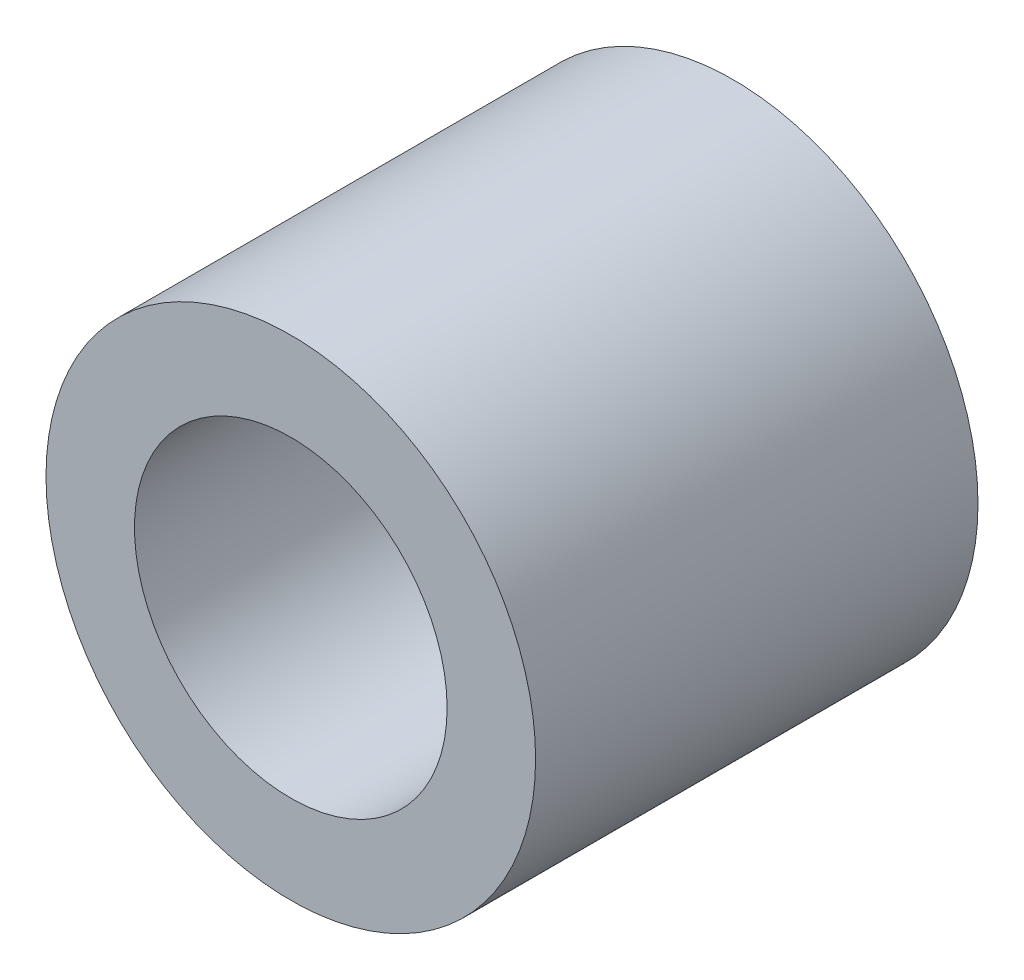
from build123d import *

# Parameters (mm, degrees)
SKETCH1_R           = 4.15
SKETCH1_R_2         = 2.65
BOSS_EXTRUDE1_DEPTH = 7.5


with BuildPart() as part:
    # Sketch1 → Boss-Extrude1 (new body)
    with BuildSketch(Plane.XY):
        Circle(SKETCH1_R)
        Circle(SKETCH1_R_2, mode=Mode.SUBTRACT)
    extrude(amount=BOSS_EXTRUDE1_DEPTH)


solid = part.part
